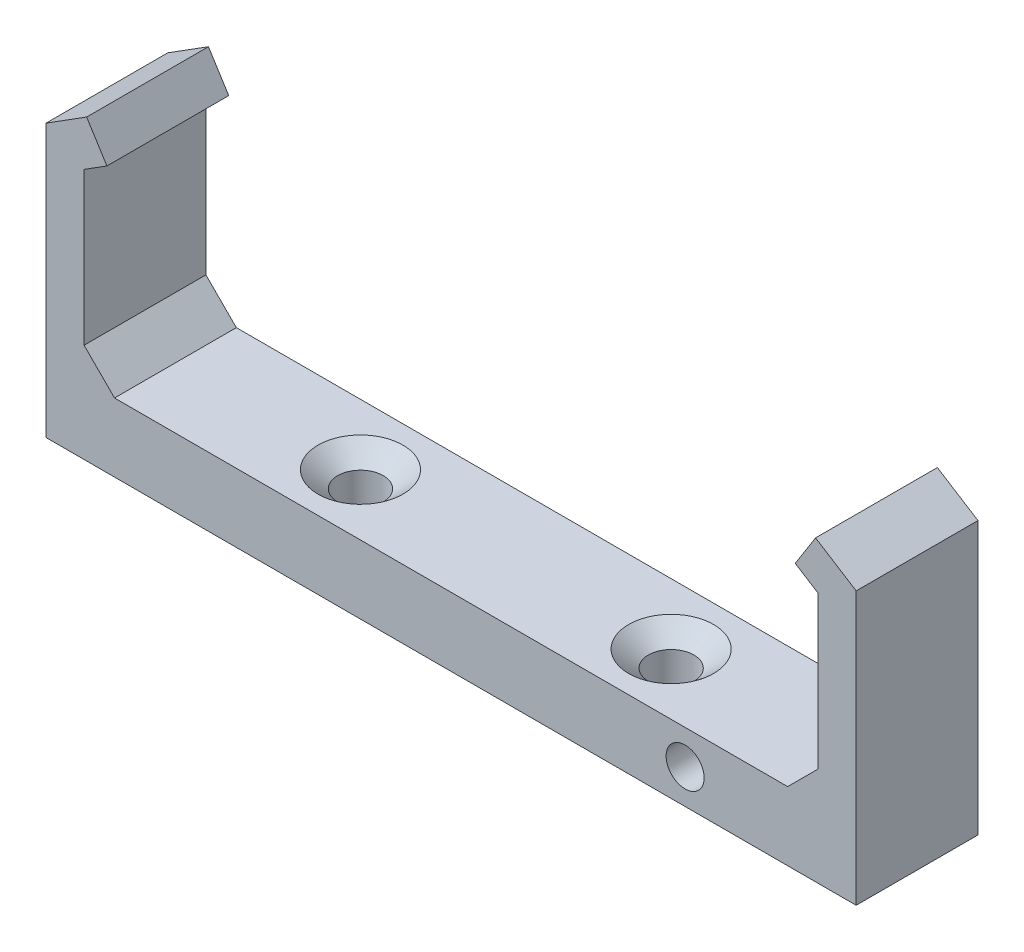
from build123d import *

# Parameters (mm, degrees)
BOSS_EXTRUDE1_DEPTH                               = 5.08
BOSS_EXTRUDE1_DEPTH_BACK                          = 5.08
CUT_EXTRUDE1_DEPTH                                = 3.175
CUT_EXTRUDE1_DEPTH_BACK                           = 11.557
SKETCH2_R                                         = 1.5875
CHAMFER1_SIZE                                     = 2.54
CHAMFER2_SIZE                                     = 2.54
CSK_FOR_6_FLAT_HEAD_MACHINE_SCREW_100_D           = 3.7973
CSK_FOR_6_FLAT_HEAD_MACHINE_SCREW_100_CSINK_D     = 7.0866
CSK_FOR_6_FLAT_HEAD_MACHINE_SCREW_100_CSINK_ANGLE = 100
BOSS_EXTRUDE2_START                               = 2.54
SKETCH6_W                                         = 67.564
SKETCH6_H                                         = 10.16
SKETCH6_R                                         = 1.89865
BOSS_EXTRUDE2_DEPTH                               = 2.54
CUT_EXTRUDE2_DEPTH                                = 40.460063647
CUT_EXTRUDE2_DEPTH_BACK                           = 40.460063647
SKETCH7_R                                         = 1.5875


with BuildPart() as part:
    # Sketch1 → Boss-Extrude1 (new, two sides: drawn at the far end of the back side and taken through both)
    with BuildSketch(Plane.XY.offset(-BOSS_EXTRUDE1_DEPTH_BACK)):
        Polygon((30.2895, 0.070457444), (-0.3175, 0.070457444), (-30.9245, 0.070457444), (-30.9245, 15.310457444), (-29.0195, 16.51), (-30.711281219, 19.196726876), (-34.0995, 17.06322944), (-34.0995, -3.104542556), (33.4645, -3.104542556), (33.4645, 17.06322944), (30.076281219, 19.196726876), (28.3845, 16.51), (30.2895, 15.310457444), align=None)
    extrude(amount=BOSS_EXTRUDE1_DEPTH + BOSS_EXTRUDE1_DEPTH_BACK)

    # Sketch2 → Cut-Extrude1 (cut, two sides: drawn at the far end of the back side and taken through both)
    with BuildSketch(Plane(origin=(0, 0, 0), x_dir=(1, 0, 0), z_dir=(0, 1, 0)).offset(-CUT_EXTRUDE1_DEPTH_BACK)):
        with Locations((-12.954, 0)):
            Circle(SKETCH2_R)
        with Locations((12.954, 0)):
            Circle(SKETCH2_R)
    extrude(amount=CUT_EXTRUDE1_DEPTH + CUT_EXTRUDE1_DEPTH_BACK, mode=Mode.SUBTRACT)

    # Chamfer1
    chamfer1_edges = [part.edges().sort_by_distance(p)[0] for p in [
        (30.2895, 0.070457444, 0),
    ]]
    chamfer(chamfer1_edges, length=CHAMFER1_SIZE)

    # Chamfer2
    chamfer2_edges = [part.edges().sort_by_distance(p)[0] for p in [
        (-30.9245, 0.070457444, 0),
    ]]
    chamfer(chamfer2_edges, length=CHAMFER2_SIZE)

    # CSK for _6 Flat Head Machine Screw _100 (through all)
    with Locations(Plane(origin=(-12.954, 0.070457444, 0), x_dir=(1, 0, 0), z_dir=(0, 1, 0))):
        with Locations((0, 0), (25.908, 0)):
            CounterSinkHole(CSK_FOR_6_FLAT_HEAD_MACHINE_SCREW_100_D / 2, CSK_FOR_6_FLAT_HEAD_MACHINE_SCREW_100_CSINK_D / 2, counter_sink_angle=CSK_FOR_6_FLAT_HEAD_MACHINE_SCREW_100_CSINK_ANGLE)

    # Sketch6 → Boss-Extrude2 (add)
    with BuildSketch(Plane(origin=(0, -3.104542556, 0), x_dir=(-1, 0, 0), z_dir=(0, -1, 0)).offset(BOSS_EXTRUDE2_START)):
        with Locations((0.3175, 0)):
            Rectangle(SKETCH6_W, SKETCH6_H)
        with Locations((12.954, 0)):
            Circle(SKETCH6_R, mode=Mode.SUBTRACT)
        with Locations((-12.954, 0)):
            Circle(SKETCH6_R, mode=Mode.SUBTRACT)
    extrude(amount=-BOSS_EXTRUDE2_DEPTH)

    # Sketch7 → Cut-Extrude2 (cut, two sides: drawn at the far end of the back side and taken through both)
    with BuildSketch(Plane.XY.offset(-CUT_EXTRUDE2_DEPTH_BACK)):
        with Locations((19.200527544, -2.787042556)):
            Circle(SKETCH7_R)
    extrude(amount=CUT_EXTRUDE2_DEPTH + CUT_EXTRUDE2_DEPTH_BACK, mode=Mode.SUBTRACT)


solid = part.part
